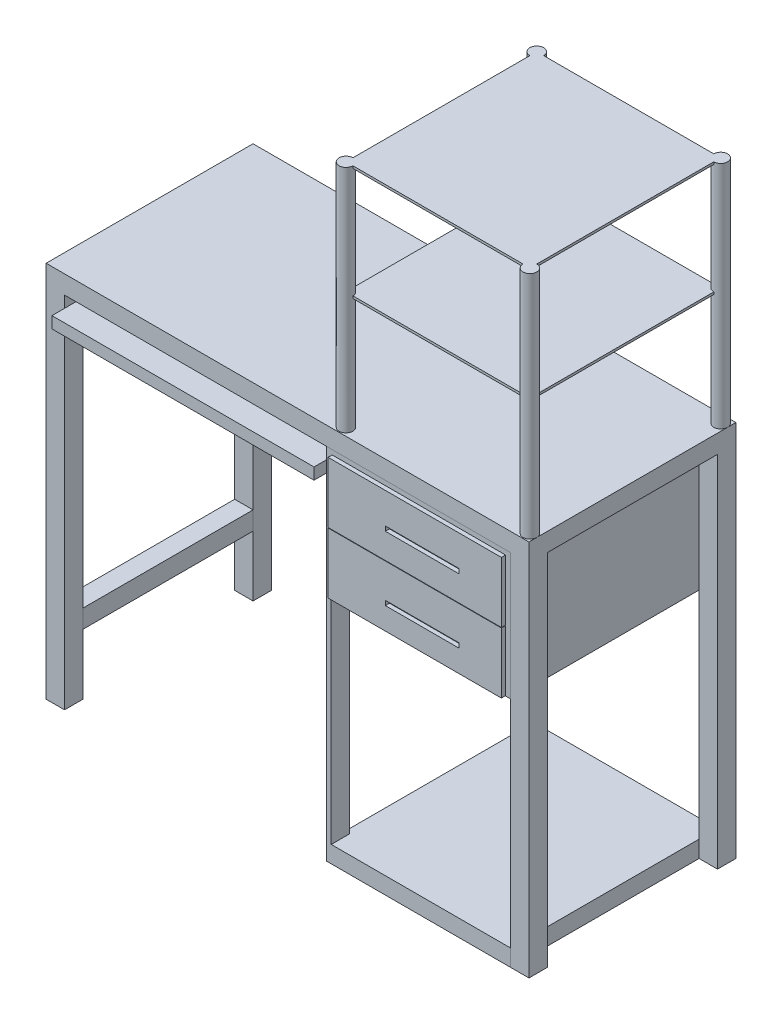
from build123d import *

# Parameters (mm, degrees)
SKETCH1_W               = 1050
SKETCH1_H               = 40
BOSS_EXTRUDE1_DEPTH     = 450
SKETCH2_W               = 40
SKETCH2_H               = 40
BOSS_EXTRUDE2_DEPTH     = 781.17
SKETCH3_W               = 400
SKETCH3_H               = 781.17
BOSS_EXTRUDE3_DEPTH     = 450
SKETCH4_W               = 570
SKETCH4_H               = 477.383383723
BOSS_EXTRUDE4_DEPTH     = 50
SKETCH5_W               = 376.924947462
SKETCH5_H               = 132
SKETCH5_W_2             = 160.246518918
SKETCH5_H_2             = 10
BOSS_EXTRUDE5_DEPTH     = 9
BOSS_EXTRUDE5_2_DEPTH   = 9
BOSS_EXTRUDE5_3_DEPTH   = 9
SKETCH6_W               = 390
SKETCH6_H               = 469.049896927
CUT_EXTRUDE1_DEPTH      = 358
CUT_EXTRUDE1_DEPTH_BACK = 451
SKETCH7_W               = 370
SKETCH7_H               = 470
CUT_EXTRUDE2_DEPTH      = 10
SKETCH8_W               = 40
SKETCH8_H               = 40
BOSS_EXTRUDE6_DEPTH     = 370
SKETCH9_W               = 570
SKETCH9_H               = 25
CUT_EXTRUDE3_DEPTH      = 478.383383723
SKETCH10_R              = 15
BOSS_EXTRUDE7_DEPTH     = 500
SKETCH11_W              = 400
SKETCH11_H              = 414.869163102
BOSS_EXTRUDE8_DEPTH     = 5
SKETCH12_W              = 400.424919487
SKETCH12_H              = 414.869163102
BOSS_EXTRUDE9_DEPTH     = 5


with BuildPart() as part:
    # Sketch1 → Boss-Extrude1 (new body)
    with BuildSketch(Plane.XY):
        with Locations((-525, -20)):
            Rectangle(SKETCH1_W, SKETCH1_H)
    extrude(amount=BOSS_EXTRUDE1_DEPTH)

    # Sketch2 → Boss-Extrude2 (add)
    with BuildSketch(Plane.XZ.offset(40)):
        with Locations((-1030, 430)):
            Rectangle(SKETCH2_W, SKETCH2_H)
        with Locations((-1030, 20)):
            Rectangle(SKETCH2_W, SKETCH2_H)
        with Locations((-20, 20)):
            Rectangle(SKETCH2_W, SKETCH2_H)
        with Locations((-20, 430)):
            Rectangle(SKETCH2_W, SKETCH2_H)
    extrude(amount=BOSS_EXTRUDE2_DEPTH)

    # Sketch10 → Boss-Extrude7 (add)
    with BuildSketch(Plane(origin=(0, 0, 0), x_dir=(1, 0, 0), z_dir=(0, 1, 0))):
        with Locations((-15, -432.902277584)):
            Circle(SKETCH10_R)
        with Locations((-15, -18.033114482)):
            Circle(SKETCH10_R)
        with Locations((-415, -432.902277584)):
            Circle(SKETCH10_R)
        with Locations((-415, -18.033114482)):
            Circle(SKETCH10_R)
    extrude(amount=BOSS_EXTRUDE7_DEPTH)

    # Sketch11 → Boss-Extrude8 (add)
    with BuildSketch(Plane(origin=(0, 500, 0), x_dir=(1, 0, 0), z_dir=(0, 1, 0))):
        with Locations((-215, -225.467696033)):
            Rectangle(SKETCH11_W, SKETCH11_H)
    extrude(amount=-BOSS_EXTRUDE8_DEPTH)

    # Sketch12 → Boss-Extrude9 (add)
    with BuildSketch(Plane(origin=(0, 250, 0), x_dir=(1, 0, 0), z_dir=(0, 1, 0))):
        with Locations((-215.212459744, -225.467696033)):
            Rectangle(SKETCH12_W, SKETCH12_H)
    extrude(amount=BOSS_EXTRUDE9_DEPTH)


with BuildPart() as body_2:
    # Sketch3 → Boss-Extrude3 (new body)
    with BuildSketch(Plane.XY.offset(450)):
        with Locations((-240, -430.585)):
            Rectangle(SKETCH3_W, SKETCH3_H)
    extrude(amount=-BOSS_EXTRUDE3_DEPTH)


with BuildPart() as body_3:
    # Sketch4 → Boss-Extrude4 (new body)
    with BuildSketch(Plane.XZ.offset(40)):
        with Locations((-725, 238.691691862)):
            Rectangle(SKETCH4_W, SKETCH4_H)
    extrude(amount=BOSS_EXTRUDE4_DEPTH)

    # Sketch9 → Cut-Extrude3 (cut, through all)
    with BuildSketch(Plane.XY.offset(477.383383723)):
        with Locations((-725, -52.5)):
            Rectangle(SKETCH9_W, SKETCH9_H)
    extrude(amount=-CUT_EXTRUDE3_DEPTH, mode=Mode.SUBTRACT)


with BuildPart() as body_4:
    # Sketch5 → Boss-Extrude5 (new body)
    with BuildSketch(Plane.XY.offset(450)):
        with Locations((-239.438560154, -382)):
            Rectangle(SKETCH5_W, SKETCH5_H)
        with Locations((-223.271719618, -402)):
            Rectangle(SKETCH5_W_2, SKETCH5_H_2, mode=Mode.SUBTRACT)
    extrude(amount=BOSS_EXTRUDE5_DEPTH)


with BuildPart() as body_5:
    # Sketch5 → Boss-Extrude5 2 (new body)
    with BuildSketch(Plane.XY.offset(450)):
        with Locations((-239.438560154, -249)):
            Rectangle(SKETCH5_W, SKETCH5_H)
        with Locations((-223.271719618, -262)):
            Rectangle(SKETCH5_W_2, SKETCH5_H_2, mode=Mode.SUBTRACT)
    extrude(amount=BOSS_EXTRUDE5_2_DEPTH)


with BuildPart() as body_6:
    # Sketch5 → Boss-Extrude5 3 (new body)
    with BuildSketch(Plane.XY.offset(450)):
        with Locations((-239.438560154, -116)):
            Rectangle(SKETCH5_W, SKETCH5_H)
        with Locations((-223.271719618, -122)):
            Rectangle(SKETCH5_W_2, SKETCH5_H_2, mode=Mode.SUBTRACT)
    extrude(amount=BOSS_EXTRUDE5_3_DEPTH)


with BuildPart() as cut_extrude1_tool:
    # Sketch6 → Cut-Extrude1 (new body, two sides)
    with BuildSketch(Plane.XY.offset(450)) as cut_extrude1_sk:
        with Locations((-235, -550.116171594)):
            Rectangle(SKETCH6_W, SKETCH6_H)
    extrude(amount=CUT_EXTRUDE1_DEPTH)
    extrude(cut_extrude1_sk.sketch, amount=-CUT_EXTRUDE1_DEPTH_BACK)


with BuildPart() as body_2_1:
    add(body_2.part)

    # Cut-Extrude1: cut by cut_extrude1_tool
    add(cut_extrude1_tool.part, mode=Mode.SUBTRACT)

    # Sketch7 → Cut-Extrude2 (cut)
    with BuildSketch(Plane(origin=(-430, 0, 0), x_dir=(0, 0, -1), z_dir=(1, 0, 0))):
        with Locations((-225, -549.641120058)):
            Rectangle(SKETCH7_W, SKETCH7_H)
    extrude(amount=-CUT_EXTRUDE2_DEPTH, mode=Mode.SUBTRACT)


with BuildPart() as body_4_1:
    add(body_4.part)

    # Cut-Extrude1: cut by cut_extrude1_tool
    add(cut_extrude1_tool.part, mode=Mode.SUBTRACT)


with BuildPart() as body_6_2:
    # Sketch8 → Boss-Extrude6 (new body)
    with BuildSketch(Plane.XY.offset(40)):
        with Locations((-1030, -669.535034358)):
            Rectangle(SKETCH8_W, SKETCH8_H)
    extrude(amount=BOSS_EXTRUDE6_DEPTH)


solid = Compound([part.part, body_3.part, body_5.part, body_6.part, body_2_1.part, body_6_2.part])
